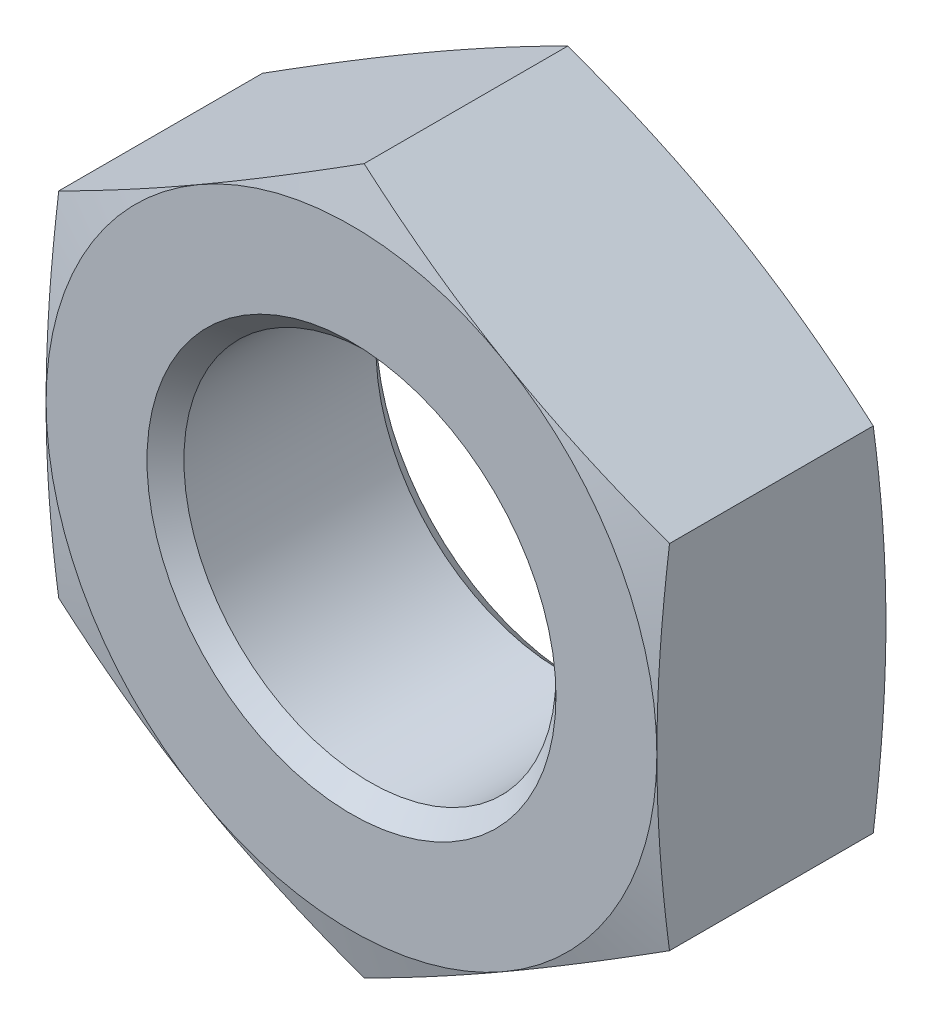
from build123d import *

# Parameters (mm, degrees)
SKETCH2_W          = 56.896
SKETCH2_H          = 56.896
CUT_EXTRUDE1_DEPTH = 10.668


with BuildPart() as part:
    # Sketch1 → Revolve1 (revolve)
    with BuildSketch(Plane(origin=(0, 0, 0), x_dir=(0, 0, -1), z_dir=(1, 0, 0))):
        Polygon((0, 0), (0, 14.224), (0.762261863, 17.0688), (9.905738137, 17.0688), (10.668, 14.224), (10.668, 0), align=None)
    revolve(axis=Axis((0, 0, -10.668), (0, 0, 1)))

    # Sketch2 → Cut-Extrude1 (cut)
    with BuildSketch(Plane.XY):
        Rectangle(SKETCH2_W, SKETCH2_H)
        Polygon((-14.224, 8.212230229), (-14.224, -8.212230229), (0, -16.424460458), (14.224, -8.212230229), (14.224, 8.212230229), (0, 16.424460458), align=None, mode=Mode.SUBTRACT)
    extrude(amount=-CUT_EXTRUDE1_DEPTH, mode=Mode.SUBTRACT)

    # Sketch3 → Cut-Revolve1 (revolve, cut)
    with BuildSketch(Plane(origin=(0, 0, 0), x_dir=(0, 0, -1), z_dir=(1, 0, 0))):
        Polygon((0, 0), (0, 9.525), (0.85979, 8.66521), (9.80821, 8.66521), (10.668, 9.525), (10.668, 0), align=None)
    revolve(axis=Axis((0, 0, -10.668), (0, 0, 1)), mode=Mode.SUBTRACT)


solid = part.part
